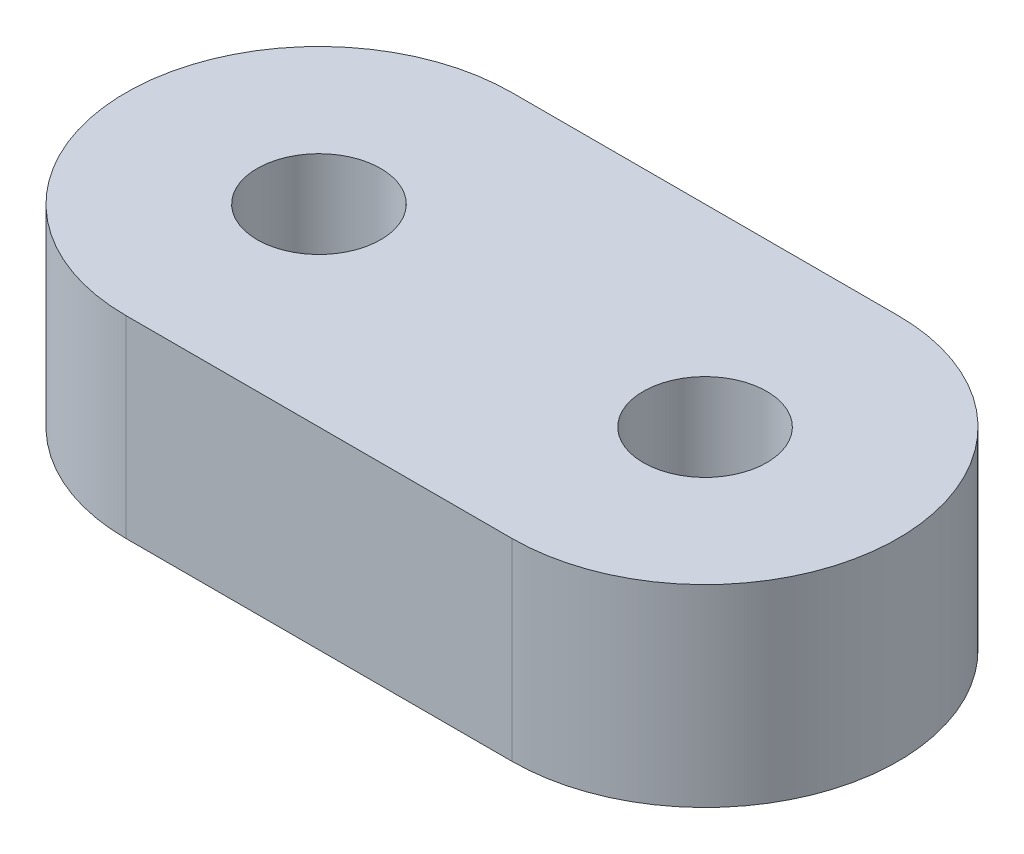
from build123d import *

# Parameters (mm, degrees)
SKETCH1_R           = 1.6
BOSS_EXTRUDE1_DEPTH = 2.5


with BuildPart() as part:
    # Sketch1 → Boss-Extrude1 (new body, symmetric)
    with BuildSketch(Plane(origin=(0, 0, 0), x_dir=(1, 0, 0), z_dir=(0, 1, 0))):
        with BuildLine():
            Line((5, -5), (-5, -5))
            ThreePointArc((-5, -5), (-10, 0), (-5, 5))
            Line((-5, 5), (5, 5))
            ThreePointArc((5, 5), (10, 0), (5, -5))
        make_face()
        with Locations((-5, 0)):
            Circle(SKETCH1_R, mode=Mode.SUBTRACT)
        with Locations((5, 0)):
            Circle(SKETCH1_R, mode=Mode.SUBTRACT)
    extrude(amount=BOSS_EXTRUDE1_DEPTH, both=True)


solid = part.part
